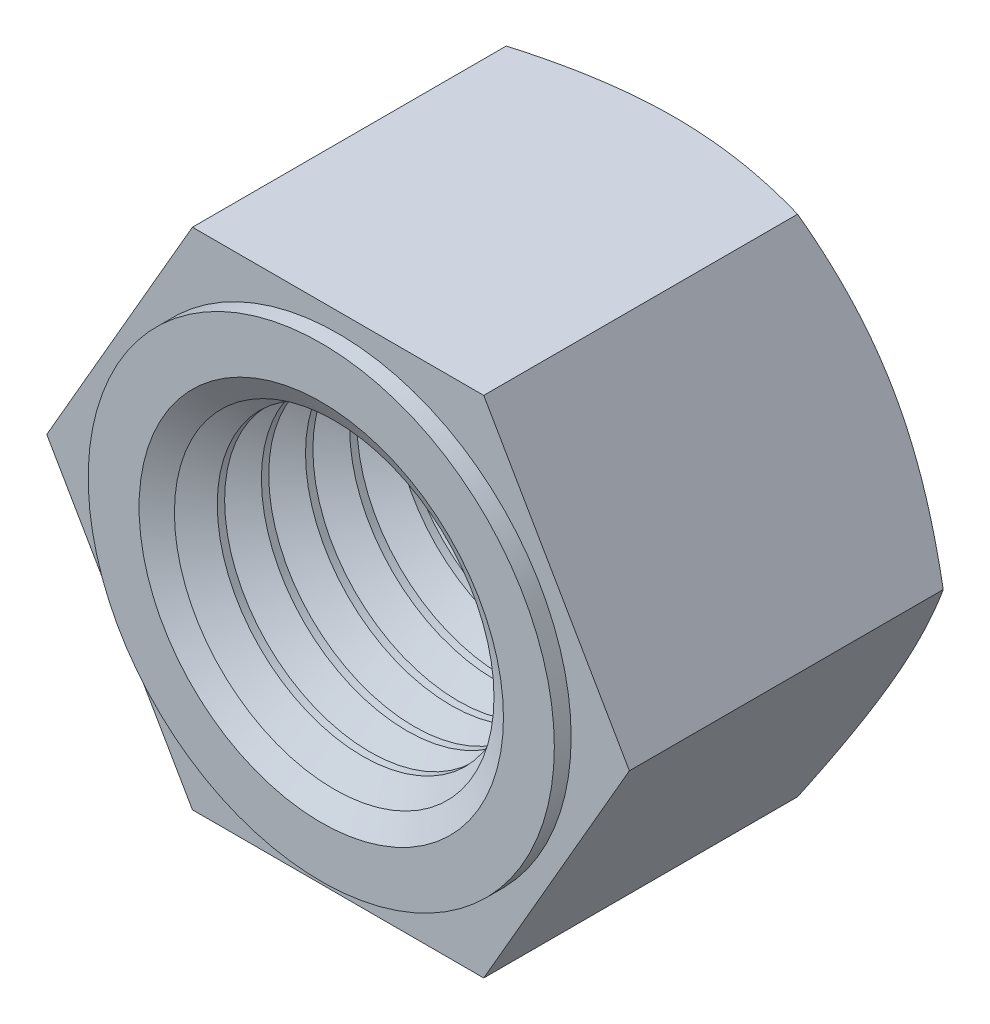
from build123d import *

# Parameters (mm, degrees)
SKETCH1_R         = 5.188
BASENUT_DEPTH     = 12
SKETCH3_R         = 8.315
SKETCH3_R_2       = 5.188
EXTRUDE1_DEPTH    = 0.6
ENDCHAMFER3_SIZE  = 1.312
ENDCHAMFER3_SIZE2 = 0.757483553
LPATTERN10_COUNT  = 8
LPATTERN10_PITCH  = 1.5744


with BuildPart() as part:
    # Sketch1 → BaseNut (new body)
    with BuildSketch(Plane.XY):
        Polygon((5.196152423, -9), (10.392304845, 0), (5.196152423, 9), (-5.196152423, 9), (-10.392304845, 0), (-5.196152423, -9), align=None)
        Circle(SKETCH1_R, mode=Mode.SUBTRACT)
    extrude(amount=-BASENUT_DEPTH)

    # Sketch2 → Chamfer1 (revolve, cut)
    with BuildSketch(Plane(origin=(-16.706149795, 0, -15.04811501), x_dir=(0, 0, 1), z_dir=(0, 1, 0))):
        Polygon((3.04811501, 25.706149795), (3.04811501, 27.098454641), (3.851962587, 27.098454641), align=None)
    revolve(axis=Axis((0, 0, -38.770766557), (0, 0, 1)), mode=Mode.SUBTRACT)

    # Sketch6 → EndChamfer1 (revolve, cut)
    with BuildSketch(Plane(origin=(-9.197458863, 0, -10.252541137), x_dir=(0, 0, 1), z_dir=(0, 1, 0))):
        Polygon((-1.747458863, 14.385458863), (-1.747458863, 15.697458863), (-0.989975309, 14.385458863), align=None)
    revolve(axis=Axis((0, 0, 13.104863586), (0, 0, -1)), mode=Mode.SUBTRACT)

    # Sketch3 → Extrude1 (add)
    with BuildSketch(Plane(origin=(-18.48918612, 11.17895969, 0), x_dir=(1, 0, 0), z_dir=(0, 0, 1))):
        with Locations((18.48918612, -11.17895969)):
            Circle(SKETCH3_R)
        with Locations((18.48918612, -11.17895969)):
            Circle(SKETCH3_R_2, mode=Mode.SUBTRACT)
    extrude(amount=EXTRUDE1_DEPTH)

    # EndChamfer3
    endchamfer3_edges = [part.edges().sort_by_distance(p)[0] for p in [
        (-5.188, 0, 0.6),
    ]]
    endchamfer3_side = [part.faces().sort_by_distance(p)[0] for p in [
        (-8.079816285, 0, 0.6),
    ]]
    chamfer(endchamfer3_edges, length=ENDCHAMFER3_SIZE, length2=ENDCHAMFER3_SIZE2, reference=endchamfer3_side[0])

    # Sketch7 → Cut-Revolve10 (revolve, cut)
    with BuildSketch(Plane(origin=(0, 0, 0), x_dir=(1, 0, 0), z_dir=(0, 1, 0))):
        Polygon((3.876, 11.898516447), (5.188, 11.898516447), (6.32422533, 11.242516447), (5.188, 10.586516447), (3.876, 10.586516447), align=None)
    cut_revolve10 = revolve(axis=Axis((0, 0, -61.609777784), (0, 0, 1)), mode=Mode.SUBTRACT)

    # LPattern10: Cut-Revolve10 ×8
    with Locations(*[(0, 0, i * LPATTERN10_PITCH) for i in range(1, LPATTERN10_COUNT)]):
        add(cut_revolve10, mode=Mode.SUBTRACT)


solid = part.part
